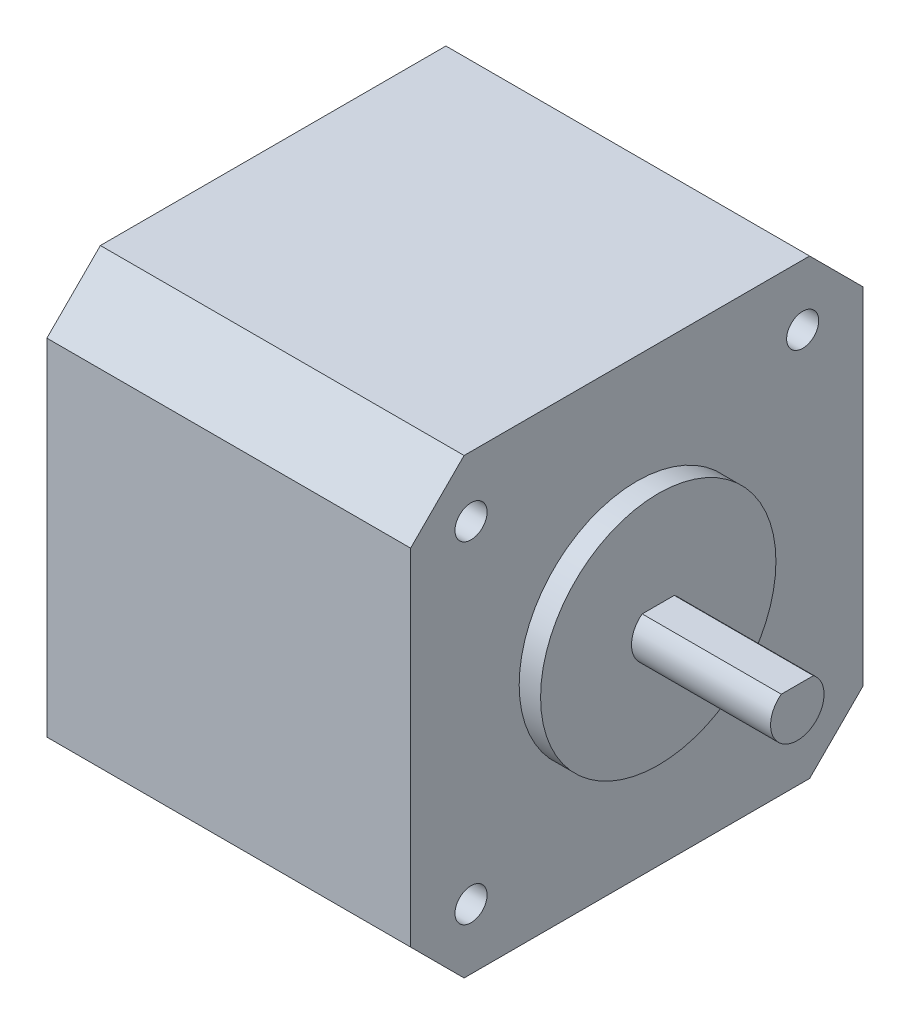
from build123d import *

# Parameters (mm, degrees)
SKETCH1_R           = 1.5
BOSS_EXTRUDE1_DEPTH = 34
SKETCH2_R           = 11
BOSS_EXTRUDE2_DEPTH = 2
BOSS_EXTRUDE3_DEPTH = 13


with BuildPart() as part:
    # Sketch1 → Boss-Extrude1 (new body)
    with BuildSketch(Plane(origin=(0, 0, 0), x_dir=(0, 0, -1), z_dir=(1, 0, 0))):
        Polygon((0, 37.3), (5, 42.3), (37.3, 42.3), (42.3, 37.3), (42.3, 5), (37.3, 0), (5, 0), (0, 5), align=None)
        with Locations((5.65, 36.65)):
            Circle(SKETCH1_R, mode=Mode.SUBTRACT)
        with Locations((36.65, 36.65)):
            Circle(SKETCH1_R, mode=Mode.SUBTRACT)
        with Locations((36.65, 5.65)):
            Circle(SKETCH1_R, mode=Mode.SUBTRACT)
        with Locations((5.65, 5.65)):
            Circle(SKETCH1_R, mode=Mode.SUBTRACT)
    extrude(amount=BOSS_EXTRUDE1_DEPTH)

    # Sketch2 → Boss-Extrude2 (add)
    with BuildSketch(Plane(origin=(34, 0, 0), x_dir=(0, 0, -1), z_dir=(1, 0, 0))):
        with Locations((21.15, 21.15)):
            Circle(SKETCH2_R)
    extrude(amount=BOSS_EXTRUDE2_DEPTH)

    # Sketch3 → Boss-Extrude3 (add)
    with BuildSketch(Plane(origin=(36, 0, 0), x_dir=(0, 0, -1), z_dir=(1, 0, 0))):
        with BuildLine():
            Line((19.65, 23.15), (22.65, 23.15))
            ThreePointArc((22.65, 23.15), (21.15, 18.65), (19.65, 23.15))
        make_face()
    extrude(amount=BOSS_EXTRUDE3_DEPTH)


solid = part.part
